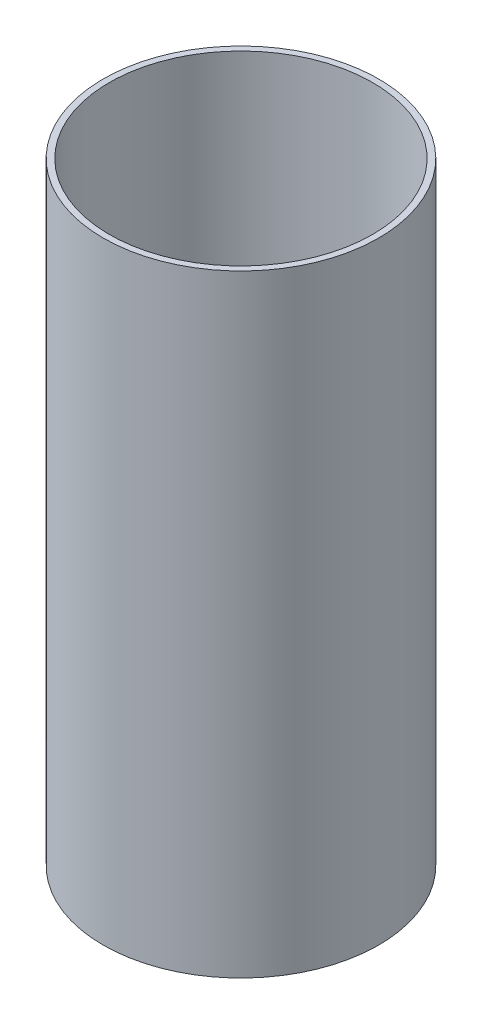
from build123d import *

# Parameters (mm, degrees)
SKETCH1_R           = 45
SKETCH1_R_2         = 43
EXTRUDE_THIN1_DEPTH = 200


with BuildPart() as part:
    # Sketch1 → Extrude-Thin1 (new body)
    with BuildSketch(Plane(origin=(0, 0, 0), x_dir=(1, 0, 0), z_dir=(0, 1, 0))):
        Circle(SKETCH1_R)
        Circle(SKETCH1_R_2, mode=Mode.SUBTRACT)
    extrude(amount=EXTRUDE_THIN1_DEPTH)


solid = part.part
